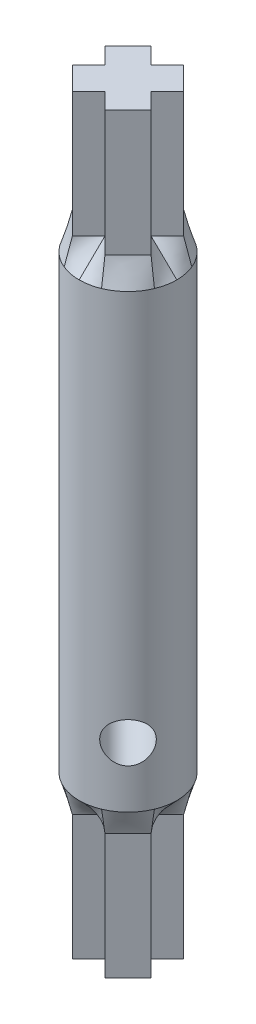
from build123d import *

# Parameters (mm, degrees)
BOSS_EXTRUDE1_DEPTH = 13.804347826
SCALE1_SCALE        = 0.92
SKETCH2_R           = 4.953
SKETCH3_R           = 4.953
BOSS_EXTRUDE2_DEPTH = 22.86
BOSS_EXTRUDE4_DEPTH = 13.804347826
SCALE2_SCALE        = 0.92
SKETCH6_R           = 2.032
CUT_EXTRUDE1_DEPTH  = 78.679240568


with BuildPart() as part:
    # Sketch1 → Boss-Extrude1 (new body)
    with BuildSketch(Plane(origin=(0, 0, 0), x_dir=(1, 0, 0), z_dir=(0, 1, 0))):
        Polygon((-0.6269783, 2.91618698), (-2.423029524, 4.712238204), (-4.963029524, 2.172238204), (-3.1669783, 0.37618698), (-4.963029524, -1.419864244), (-2.423029524, -3.959864244), (-0.6269783, -2.16381302), (1.169072924, -3.959864244), (3.709072924, -1.419864244), (1.9130217, 0.37618698), (3.709072924, 2.172238204), (1.169072924, 4.712238204), align=None)
    extrude(amount=BOSS_EXTRUDE1_DEPTH)


with BuildPart() as part_1:
    # Scale1: scaled about (-0.6269783, 6.902173913, -0.37618698)
    add(part.part.scale(SCALE1_SCALE).moved(Location((-0.050158264, 0.552173913, -0.030094958))))

    # Sketch2 → section 1 of loft1
    with BuildSketch(Plane(origin=(0, 15.792173913, 0), x_dir=(1, 0, 0), z_dir=(0, 1, 0)), mode=Mode.PRIVATE) as loft1_s1:
        with Locations((-0.6269783, 0.37618698)):
            Circle(SKETCH2_R)
    # loft from a face of the part (loft1)
    loft([part_1.faces().sort_by_distance((-0.6269783, 13.252173913, -0.37618698))[0], loft1_s1.sketch])

    # Sketch3 → Boss-Extrude2 (add)
    with BuildSketch(Plane(origin=(0, 15.792173913, 0), x_dir=(1, 0, 0), z_dir=(0, 1, 0))):
        with Locations(Location((-0.6269783, 0.37618698, 0), (0, 0, 270))):
            Circle(SKETCH3_R)
    boss_extrude2 = extrude(amount=BOSS_EXTRUDE2_DEPTH)

    # Mirror6: Boss-Extrude2 across plane
    add(boss_extrude2.mirror(Plane(origin=(-0.6269783, 38.652173913, -0.37618698), x_dir=(0, 0, 1), z_dir=(0, 1, 0))))



with BuildPart() as body_2:
    # Sketch5 → Boss-Extrude4 (new body)
    with BuildSketch(Plane(origin=(0, 63.500993913, 0), x_dir=(1, 0, 0), z_dir=(0, 1, 0))):
        Polygon((-0.6269783, 2.91618698), (-2.423029524, 4.712238204), (-4.963029524, 2.172238204), (-3.1669783, 0.37618698), (-4.963029524, -1.419864244), (-2.423029524, -3.959864244), (-0.6269783, -2.16381302), (1.169072924, -3.959864244), (3.709072924, -1.419864244), (1.9130217, 0.37618698), (3.709072924, 2.172238204), (1.169072924, 4.712238204), align=None)
    extrude(amount=BOSS_EXTRUDE4_DEPTH)


with BuildPart() as body_2_1:
    # Scale2: scaled about (-0.6269783, 70.403167826, -0.37618698)
    add(body_2.part.scale(SCALE2_SCALE).moved(Location((-0.050158264, 5.632253426, -0.030094958))))


with BuildPart() as part_2:
    add(part_1.part)

    add(body_2_1.part)  # loft2 joins it to this body
    # loft from a face of the part (loft2)
    loft([part_2.faces().sort_by_distance((-0.6269783, 61.512173913, -0.37618698))[0], part_2.faces().sort_by_distance((-0.6269783, 64.053167826, -0.37618698))[0]])

    # Sketch6 → Cut-Extrude1 (cut, through all)
    with BuildSketch(Plane(origin=(-4.003882527, 0, -4.003882527), x_dir=(-0.7071067811865471, 0, 0.7071067811865479), z_dir=(-0.7071067811865479, 0, -0.7071067811865471))):
        with Locations((0.177336243, 21.888173913)):
            Circle(SKETCH6_R)
    extrude(amount=-CUT_EXTRUDE1_DEPTH, mode=Mode.SUBTRACT)


solid = part_2.part
